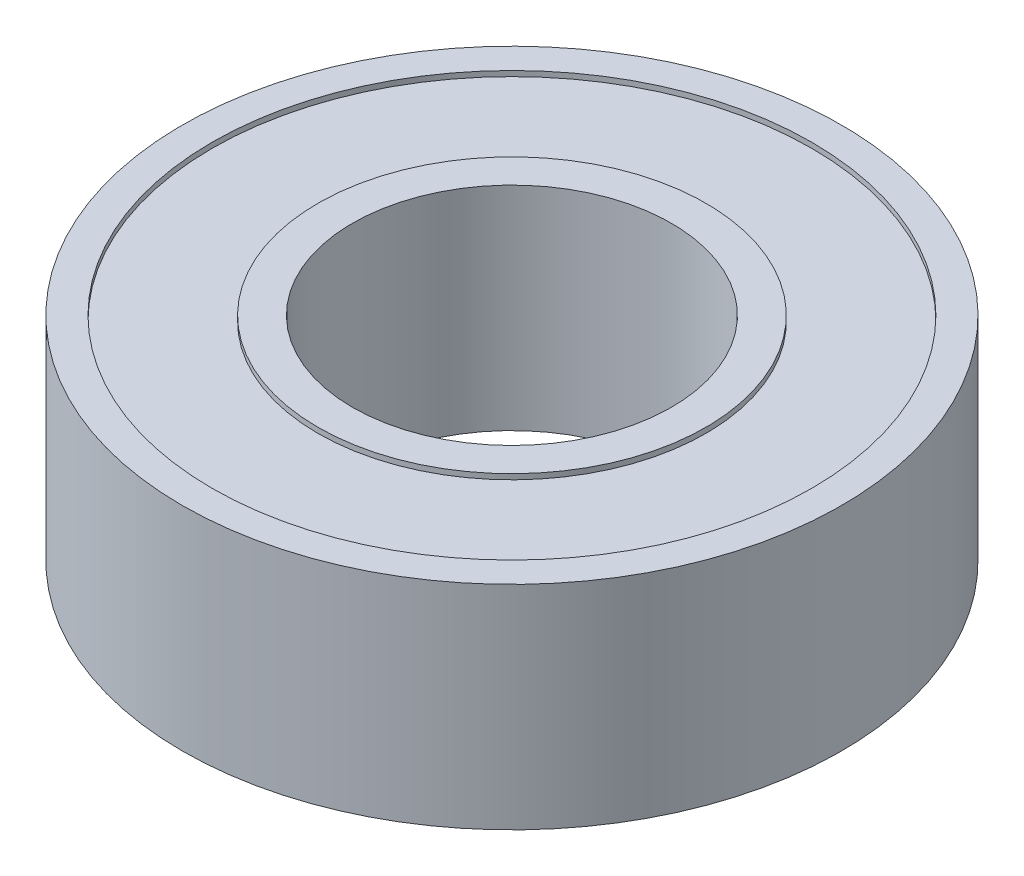
from build123d import *

# Parameters (mm, degrees)
SKETCH1_R           = 31
SKETCH1_R_2         = 15
BOSS_EXTRUDE1_DEPTH = 20
SKETCH2_R           = 28.2
SKETCH2_R_2         = 18.25
CUT_EXTRUDE1_DEPTH  = 0.5
SKETCH3_R           = 28.2
SKETCH3_R_2         = 18.25
CUT_EXTRUDE2_DEPTH  = 0.5


with BuildPart() as part:
    # Sketch1 → Boss-Extrude1 (new body)
    with BuildSketch(Plane(origin=(0, 0, 0), x_dir=(1, 0, 0), z_dir=(0, 1, 0))):
        Circle(SKETCH1_R)
        Circle(SKETCH1_R_2, mode=Mode.SUBTRACT)
    extrude(amount=BOSS_EXTRUDE1_DEPTH)

    # Sketch2 → Cut-Extrude1 (cut)
    with BuildSketch(Plane(origin=(0, 20, 0), x_dir=(1, 0, 0), z_dir=(0, 1, 0))):
        Circle(SKETCH2_R)
        Circle(SKETCH2_R_2, mode=Mode.SUBTRACT)
    extrude(amount=-CUT_EXTRUDE1_DEPTH, mode=Mode.SUBTRACT)

    # Sketch3 → Cut-Extrude2 (cut)
    with BuildSketch(Plane.XZ):
        Circle(SKETCH3_R)
        Circle(SKETCH3_R_2, mode=Mode.SUBTRACT)
    extrude(amount=-CUT_EXTRUDE2_DEPTH, mode=Mode.SUBTRACT)


solid = part.part
